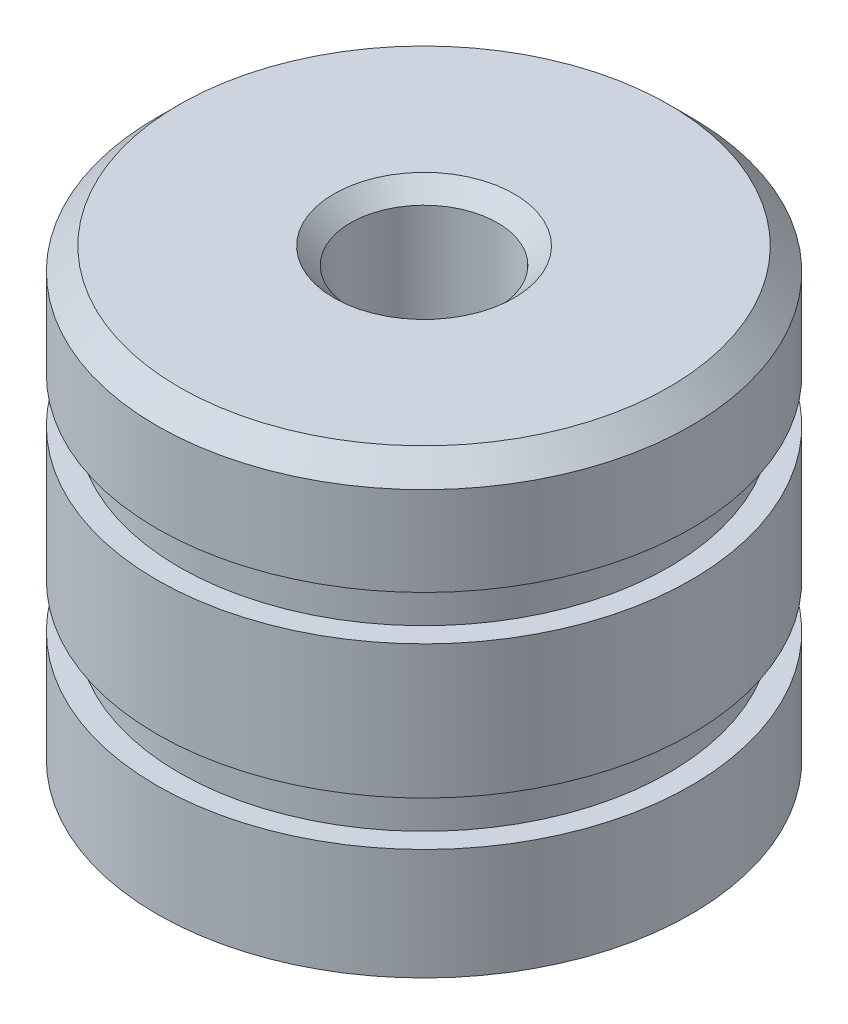
from build123d import *

# Parameters (mm, degrees)
SKETCH1_R                       = 6
BOSS_EXTRUDE1_DEPTH             = 5
CUT_EXTRUDE1_START              = -2.5
SKETCH2_R                       = 6
SKETCH2_R_2                     = 5.5
CUT_EXTRUDE1_DEPTH              = 1
CHAMFER1_SIZE                   = 0.5
M4X0_7_TAPPED_HOLE1_D           = 3.3
M4X0_7_TAPPED_HOLE1_DEPTH       = 8
M4X0_7_TAPPED_HOLE1_CSINK_D     = 4.05
M4X0_7_TAPPED_HOLE1_CSINK_ANGLE = 90
M4X0_7_TAPPED_HOLE1_TIP         = 0.991420021


with BuildPart() as part:
    # Sketch1 → Boss-Extrude1 (new body, symmetric)
    with BuildSketch(Plane(origin=(0, 0, 0), x_dir=(1, 0, 0), z_dir=(0, 1, 0))):
        Circle(SKETCH1_R)
    extrude(amount=BOSS_EXTRUDE1_DEPTH, both=True)

    # Sketch2 → Cut-Extrude1 (cut)
    with BuildSketch(Plane(origin=(0, 5, 0), x_dir=(1, 0, 0), z_dir=(0, 1, 0)).offset(CUT_EXTRUDE1_START)):
        Circle(SKETCH2_R)
        Circle(SKETCH2_R_2, mode=Mode.SUBTRACT)
    cut_extrude1 = extrude(amount=-CUT_EXTRUDE1_DEPTH, mode=Mode.SUBTRACT)

    # Mirror1: Cut-Extrude1 across plane
    add(cut_extrude1.mirror(Plane.ZX), mode=Mode.SUBTRACT)

    # Chamfer1
    chamfer1_edges = [part.edges().sort_by_distance(p)[0] for p in [
        (-6, 5, 0),
    ]]
    chamfer(chamfer1_edges, length=CHAMFER1_SIZE)

    # M4x0.7 Tapped Hole1
    with Locations(Plane(origin=(0, 5, 0), x_dir=(1, 0, 0), z_dir=(0, 1, 0))):
        with Locations((0, 0)):
            CounterSinkHole(M4X0_7_TAPPED_HOLE1_D / 2, M4X0_7_TAPPED_HOLE1_CSINK_D / 2, depth=M4X0_7_TAPPED_HOLE1_DEPTH, counter_sink_angle=M4X0_7_TAPPED_HOLE1_CSINK_ANGLE)
            with Locations((0, 0, -(M4X0_7_TAPPED_HOLE1_DEPTH + M4X0_7_TAPPED_HOLE1_TIP / 2))):  # 118° drill point
                Cone(0, M4X0_7_TAPPED_HOLE1_D / 2, M4X0_7_TAPPED_HOLE1_TIP, mode=Mode.SUBTRACT)


solid = part.part
